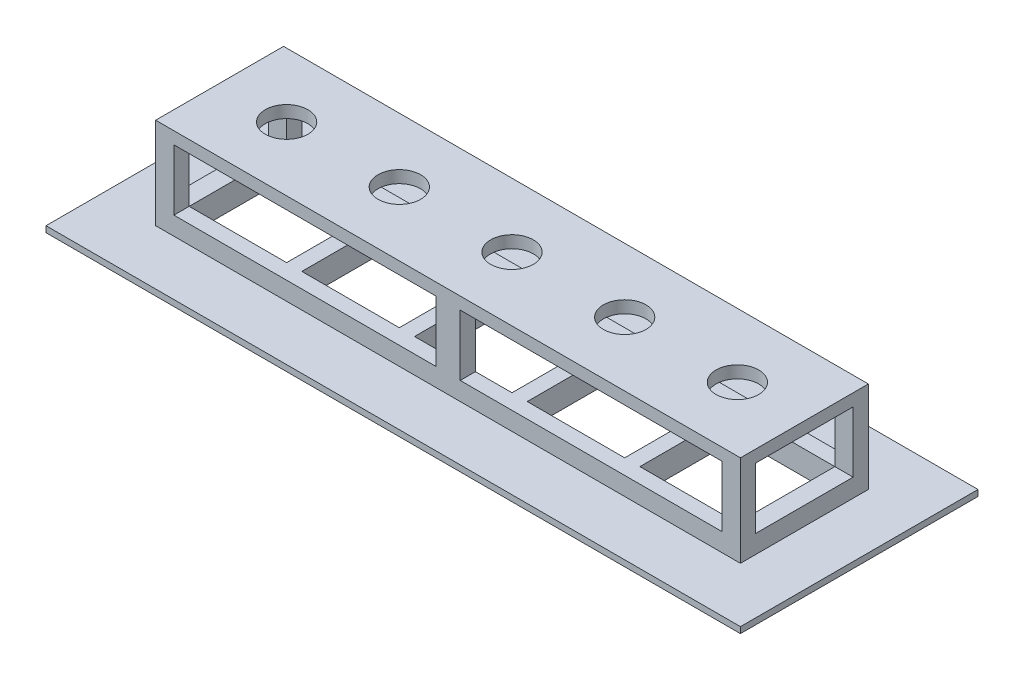
from build123d import *

# Parameters (mm, degrees)
SKETCH1_W               = 96
SKETCH1_H               = 21
BOSS_EXTRUDE1_DEPTH     = 3
CUT_EXTRUDE3_DEPTH      = 7
CUT_EXTRUDE3_DEPTH_BACK = 7
SKETCH2_W               = 16
SKETCH2_H               = 16
SKETCH5_W               = 3
SKETCH5_H               = 2.5
SKETCH5_W_2             = 4
BOSS_EXTRUDE5_DEPTH     = 10
SKETCH6_W               = 96
SKETCH6_H               = 21
BOSS_EXTRUDE6_DEPTH     = 2
SKETCH7_R               = 3.5
CUT_EXTRUDE5_DEPTH      = 2
SKETCH9_W               = 114
SKETCH9_H               = 39
BOSS_EXTRUDE7_DEPTH     = 1
SKETCH10_W              = 16
SKETCH10_H              = 16
CUT_EXTRUDE6_DEPTH      = 1


with BuildPart() as part:
    # Sketch1 → Boss-Extrude1 (new body)
    with BuildSketch(Plane(origin=(0, 0, 0), x_dir=(1, 0, 0), z_dir=(0, 1, 0))):
        Rectangle(SKETCH1_W, SKETCH1_H)
    extrude(amount=BOSS_EXTRUDE1_DEPTH)

    # Sketch2 → Cut-Extrude3 (cut, two sides: drawn at the far end of the back side and taken through both)
    with BuildSketch(Plane(origin=(0, 3, 0), x_dir=(1, 0, 0), z_dir=(0, 1, 0)).offset(-CUT_EXTRUDE3_DEPTH_BACK)):
        Rectangle(SKETCH2_W, SKETCH2_H)
        with Locations((-37, 0)):
            Rectangle(SKETCH2_W, SKETCH2_H)
        with Locations((-18.5, 0)):
            Rectangle(SKETCH2_W, SKETCH2_H)
        with Locations((18.5, 0)):
            Rectangle(SKETCH2_W, SKETCH2_H)
        with Locations((37, 0)):
            Rectangle(SKETCH2_W, SKETCH2_H)
    extrude(amount=CUT_EXTRUDE3_DEPTH + CUT_EXTRUDE3_DEPTH_BACK, mode=Mode.SUBTRACT)

    # Sketch5 → Boss-Extrude5 (add)
    with BuildSketch(Plane(origin=(0, 3, 0), x_dir=(1, 0, 0), z_dir=(0, 1, 0))):
        with Locations((-46.5, 9.25)):
            Rectangle(SKETCH5_W, SKETCH5_H)
        with Locations((0, 9.25)):
            Rectangle(SKETCH5_W_2, SKETCH5_H)
        with Locations((-46.5, -9.25)):
            Rectangle(SKETCH5_W, SKETCH5_H)
        with Locations((46.5, 9.25)):
            Rectangle(SKETCH5_W, SKETCH5_H)
        with Locations((0, -9.25)):
            Rectangle(SKETCH5_W_2, SKETCH5_H)
        with Locations((46.5, -9.25)):
            Rectangle(SKETCH5_W, SKETCH5_H)
    extrude(amount=BOSS_EXTRUDE5_DEPTH)

    # Sketch6 → Boss-Extrude6 (add)
    with BuildSketch(Plane(origin=(0, 13, 0), x_dir=(1, 0, 0), z_dir=(0, 1, 0))):
        Rectangle(SKETCH6_W, SKETCH6_H)
    extrude(amount=BOSS_EXTRUDE6_DEPTH)

    # Sketch7 → Cut-Extrude5 (cut)
    with BuildSketch(Plane(origin=(0, 15, 0), x_dir=(1, 0, 0), z_dir=(0, 1, 0))):
        with Locations((-37, 0)):
            Circle(SKETCH7_R)
        with Locations((-18.5, 0)):
            Circle(SKETCH7_R)
        Circle(SKETCH7_R)
        with Locations((18.5, 0)):
            Circle(SKETCH7_R)
        with Locations((37, 0)):
            Circle(SKETCH7_R)
    extrude(amount=-CUT_EXTRUDE5_DEPTH, mode=Mode.SUBTRACT)

    # Sketch9 → Boss-Extrude7 (add)
    with BuildSketch(Plane.XZ):
        Rectangle(SKETCH9_W, SKETCH9_H)
    extrude(amount=BOSS_EXTRUDE7_DEPTH)

    # Sketch10 → Cut-Extrude6 (cut)
    with BuildSketch(Plane.XZ.offset(1)):
        with Locations((-37, 0)):
            Rectangle(SKETCH10_W, SKETCH10_H)
        with Locations((-18.5, 0)):
            Rectangle(SKETCH10_W, SKETCH10_H)
        Rectangle(SKETCH10_W, SKETCH10_H)
        with Locations((18.5, 0)):
            Rectangle(SKETCH10_W, SKETCH10_H)
        with Locations((37, 0)):
            Rectangle(SKETCH10_W, SKETCH10_H)
    extrude(amount=-CUT_EXTRUDE6_DEPTH, mode=Mode.SUBTRACT)


solid = part.part
